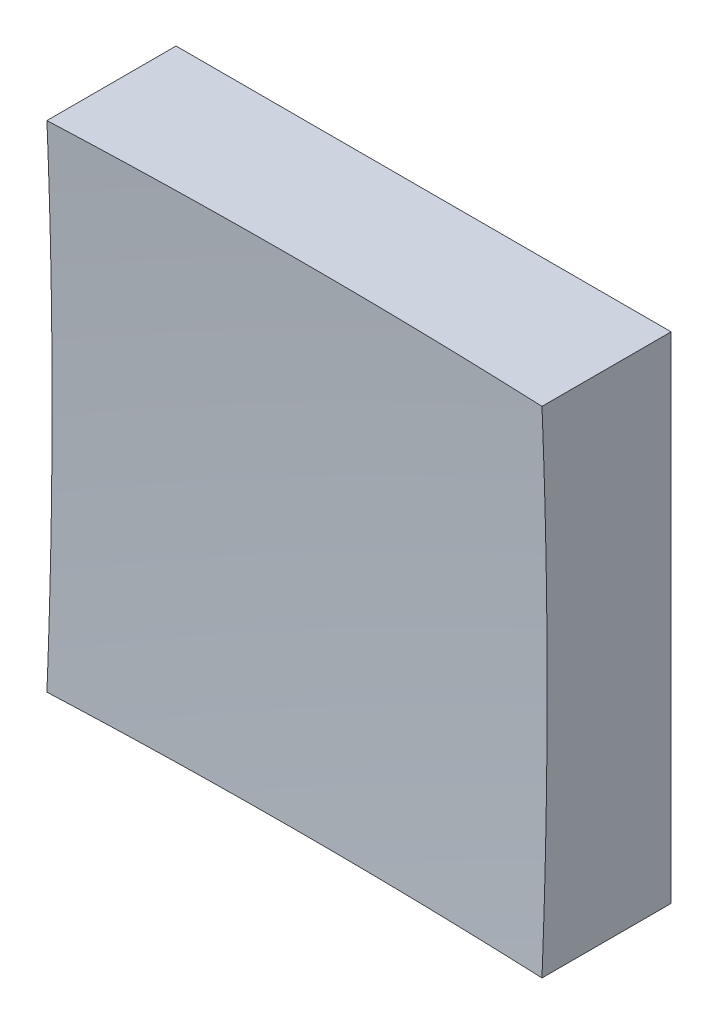
from build123d import *

# Parameters (mm, degrees)
SKETCH_1_W      = 25
SKETCH_1_H      = 25
EXTRUDE_1_DEPTH = 20


with BuildPart() as part:
    # 草图1 → 凸台-拉伸1 (new body)
    with BuildSketch(Plane.XY):
        Rectangle(SKETCH_1_W, SKETCH_1_H)
    extrude(amount=EXTRUDE_1_DEPTH)

    # 草图2 → 切除-旋转2 (revolve, cut)
    with BuildSketch(Plane(origin=(0, 0, 0), x_dir=(1, 0, 0), z_dir=(0, 1, 0))):
        with BuildLine():
            Line((292.453638544, -239.13544061), (0, -239.13544061))
            Line((0, -239.13544061), (0, -6))
            ThreePointArc((0, -6), (187.003518928, -71.41593424), (292.453638544, -239.13544061))
        make_face()
    revolve(axis=Axis((0, 0, 239.13544061), (0, 0, -1)), mode=Mode.SUBTRACT)


solid = part.part
